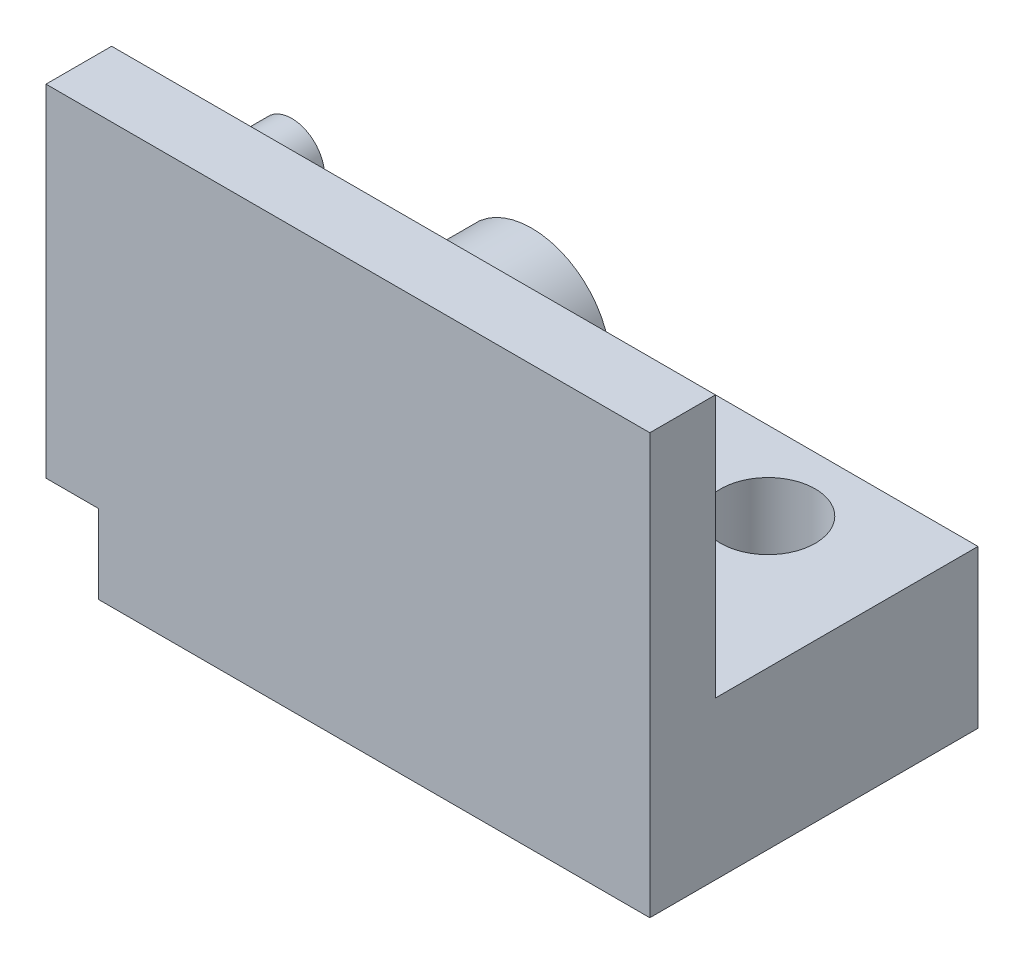
from build123d import *

# Parameters (mm, degrees)
BOSS_EXTRUDE1_DEPTH = 2.5
SKETCH2_R           = 1.25
BOSS_EXTRUDE2_DEPTH = 3.5
SKETCH3_R           = 3
BOSS_EXTRUDE3_DEPTH = 10
SKETCH4_W           = 10
SKETCH4_H           = 6
BOSS_EXTRUDE4_DEPTH = 10
SKETCH5_R           = 1.8
CUT_EXTRUDE1_DEPTH  = 7
BOSS_EXTRUDE5_DEPTH = 2.5
SKETCH8_W           = 7
SKETCH8_H           = 30
CUT_EXTRUDE2_DEPTH  = 10
SKETCH9_W           = 15.6
SKETCH9_H           = 14
CUT_EXTRUDE3_DEPTH  = 10
SKETCH10_W          = 2
SKETCH10_H          = 16
CUT_EXTRUDE4_DEPTH  = 10
SKETCH11_R          = 1.25
BOSS_EXTRUDE6_DEPTH = 3.5
SKETCH12_W          = 2
SKETCH12_H          = 3
CUT_EXTRUDE5_DEPTH  = 10


with BuildPart() as part:
    # Sketch1 → Boss-Extrude1 (new body)
    with BuildSketch(Plane.XY):
        Polygon((-47.040141431, -25.701123128), (-19.040141431, -25.701123128), (-19.040141431, 4.298876872), (-29.040141431, 4.298876872), (-47.040141431, -15.701123128), align=None)
    extrude(amount=BOSS_EXTRUDE1_DEPTH)

    # Sketch2 → Boss-Extrude2 (add)
    with BuildSketch(Plane(origin=(0, 0, 0), x_dir=(-1, 0, 0), z_dir=(0, 0, -1))):
        with Locations((23.040141431, -0.081123128)):
            Circle(SKETCH2_R)
    extrude(amount=BOSS_EXTRUDE2_DEPTH)

    # Sketch3 → Boss-Extrude3 (add)
    with BuildSketch(Plane(origin=(0, 0, 0), x_dir=(-1, 0, 0), z_dir=(0, 0, -1))):
        with Locations((43.040141431, -20.701123128)):
            Circle(SKETCH3_R)
    extrude(amount=BOSS_EXTRUDE3_DEPTH)

    # Sketch4 → Boss-Extrude4 (add)
    with BuildSketch(Plane(origin=(0, 0, 0), x_dir=(-1, 0, 0), z_dir=(0, 0, -1))):
        with Locations((31.040141431, -22.701123128)):
            Rectangle(SKETCH4_W, SKETCH4_H)
    extrude(amount=BOSS_EXTRUDE4_DEPTH)

    # Sketch5 → Cut-Extrude1 (cut, through all)
    with BuildSketch(Plane(origin=(0, -19.701123128, 0), x_dir=(1, 0, 0), z_dir=(0, 1, 0))):
        with Locations((-31.040141431, 7)):
            Circle(SKETCH5_R)
    extrude(amount=-CUT_EXTRUDE1_DEPTH, mode=Mode.SUBTRACT)

    # Sketch6 → Boss-Extrude5 (add)
    with BuildSketch(Plane(origin=(0, 0, 0), x_dir=(-1, 0, 0), z_dir=(0, 0, -1))):
        Polygon((47.040141431, -25.701123128), (51.040141431, -25.701123128), (51.040141431, -9.701123128), (41.640141431, -9.701123128), (47.040141431, -15.701123128), align=None)
    extrude(amount=-BOSS_EXTRUDE5_DEPTH)

    # Sketch8 → Cut-Extrude2 (cut)
    with BuildSketch(Plane(origin=(0, 0, -3.5), x_dir=(-1, 0, 0), z_dir=(0, 0, -1))):
        with Locations((22.540141431, -10.701123128)):
            Rectangle(SKETCH8_W, SKETCH8_H)
    extrude(amount=-CUT_EXTRUDE2_DEPTH, mode=Mode.SUBTRACT)

    # Sketch9 → Cut-Extrude3 (cut)
    with BuildSketch(Plane(origin=(0, 0, 0), x_dir=(-1, 0, 0), z_dir=(0, 0, -1))):
        with Locations((33.840141431, -2.701123128)):
            Rectangle(SKETCH9_W, SKETCH9_H)
    extrude(amount=-CUT_EXTRUDE3_DEPTH, mode=Mode.SUBTRACT)

    # Sketch10 → Cut-Extrude4 (cut)
    with BuildSketch(Plane(origin=(0, 0, 0), x_dir=(-1, 0, 0), z_dir=(0, 0, -1))):
        with Locations((50.040141431, -17.701123128)):
            Rectangle(SKETCH10_W, SKETCH10_H)
    extrude(amount=-CUT_EXTRUDE4_DEPTH, mode=Mode.SUBTRACT)

    # Sketch11 → Boss-Extrude6 (add)
    with BuildSketch(Plane(origin=(0, 0, 0), x_dir=(-1, 0, 0), z_dir=(0, 0, -1))):
        with Locations((45.680141431, -13.401123128)):
            Circle(SKETCH11_R)
    extrude(amount=BOSS_EXTRUDE6_DEPTH)

    # Sketch12 → Cut-Extrude5 (cut)
    with BuildSketch(Plane(origin=(0, 0, 0), x_dir=(-1, 0, 0), z_dir=(0, 0, -1))):
        with Locations((48.040141431, -24.201123128)):
            Rectangle(SKETCH12_W, SKETCH12_H)
    extrude(amount=-CUT_EXTRUDE5_DEPTH, mode=Mode.SUBTRACT)


solid = part.part
